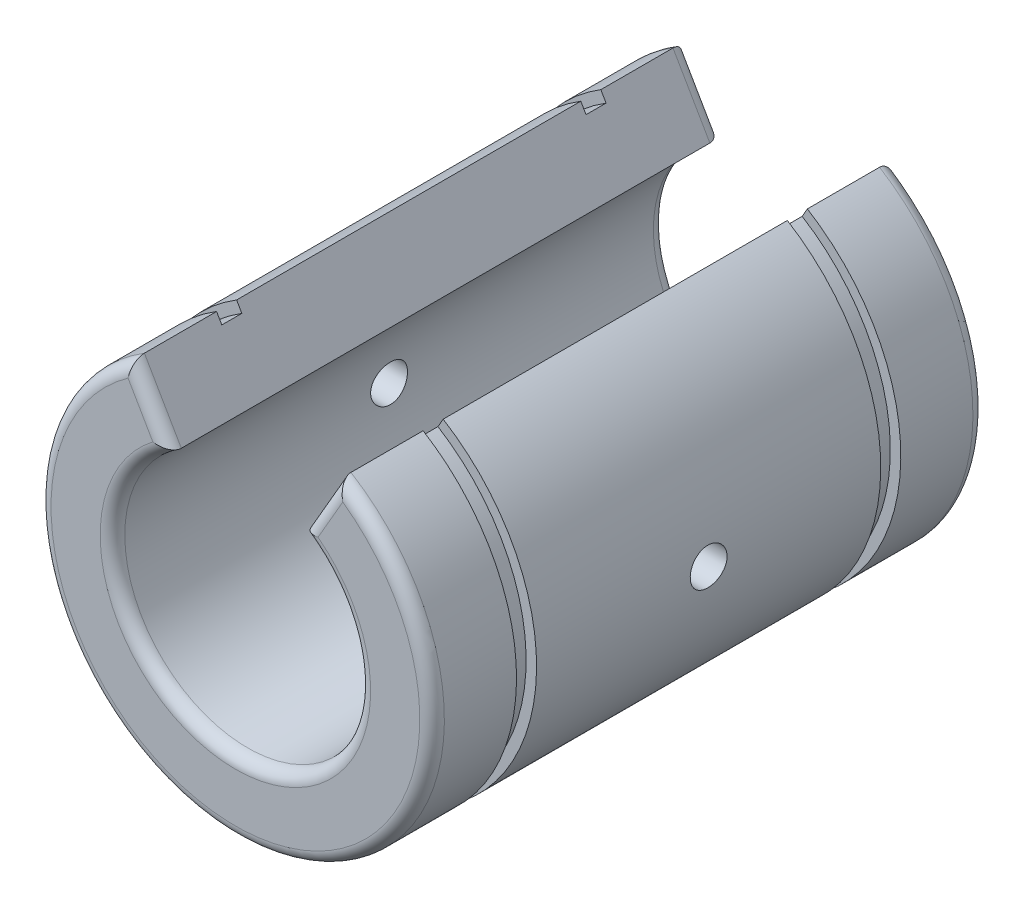
from build123d import *

# Parameters (mm, degrees)
EXTRUDE1_DEPTH      = 22.5
SKETCH2_R           = 16
SKETCH2_R_2         = 15.15
EXTRUDE2_DEPTH      = 1.63
FILLET1_R           = 1
SKETCH3_R           = 1.5
EXTRUDE3_DEPTH      = 17.0000001
EXTRUDE3_DEPTH_BACK = 17.0000001


with BuildPart() as part:
    # Sketch1 → Extrude1 (new body, symmetric)
    with BuildSketch(Plane.XY):
        with BuildLine():
            Line((5.4, 8.416650165), (8.402057485, 13.616366256))
            ThreePointArc((8.402057485, 13.616366256), (0, -16), (-8.402057485, 13.616366256))
            Line((-8.402057485, 13.616366256), (-5.4, 8.416650165))
            ThreePointArc((-5.4, 8.416650165), (0, -10), (5.4, 8.416650165))
        make_face()
    extrude(amount=EXTRUDE1_DEPTH, both=True)

    # Sketch2 → Extrude2 (cut)
    with BuildSketch(Plane.XY.offset(14)):
        Circle(SKETCH2_R)
        Circle(SKETCH2_R_2, mode=Mode.SUBTRACT)
    extrude2 = extrude(amount=EXTRUDE2_DEPTH, mode=Mode.SUBTRACT)

    # Fillet1
    fillet1_edges = [part.edges().sort_by_distance(p)[0] for p in [
        (0, -16, 22.5),
        (6.901028742, 11.016508211, 22.5),
        (0, -10, 22.5),
        (6.901028742, 11.016508211, -22.5),
        (0, -16, -22.5),
        (-6.901028742, 11.016508211, -22.5),
        (0, -10, -22.5),
        (-6.901028742, 11.016508211, 22.5),
    ]]
    fillet(fillet1_edges, radius=FILLET1_R)

    # Mirror1: Extrude2 across plane
    add(extrude2.mirror(Plane.XY), mode=Mode.SUBTRACT)

    # Sketch3 → Extrude3 (cut, two sides)
    with BuildSketch(Plane(origin=(0, 0, 0), x_dir=(0, 0, -1), z_dir=(1, 0, 0))) as extrude3_sk:
        Circle(SKETCH3_R)
    extrude(amount=EXTRUDE3_DEPTH, mode=Mode.SUBTRACT)
    extrude(extrude3_sk.sketch, amount=-EXTRUDE3_DEPTH_BACK, mode=Mode.SUBTRACT)


solid = part.part
